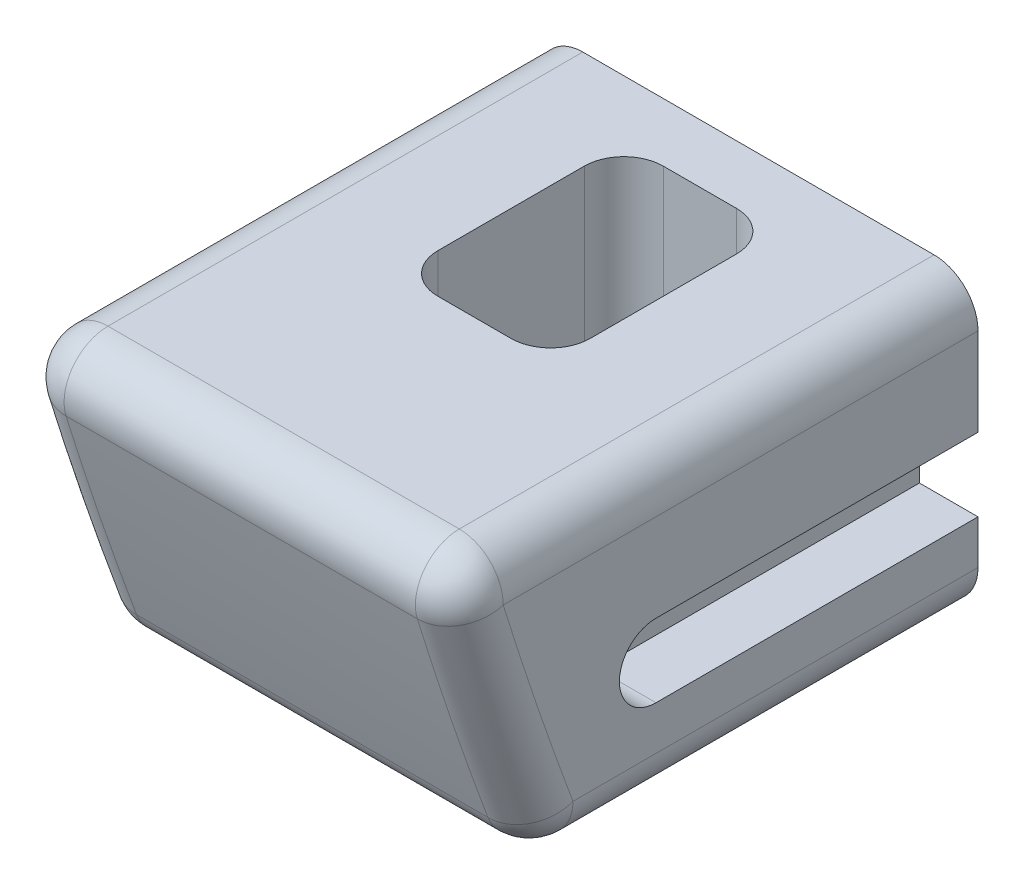
from build123d import *

# Parameters (mm, degrees)
SKETCH1_W               = 15
SKETCH1_H               = 8
BOSS_EXTRUDE1_DEPTH     = 10
CUT_EXTRUDE1_DEPTH      = 9
BOSS_EXTRUDE2_DEPTH     = 15
CUT_EXTRUDE2_DEPTH      = 2
SKETCH6_R               = 0.8
CUT_EXTRUDE3_DEPTH      = 9
CUT_EXTRUDE3_DEPTH_BACK = 3
FILLET1_R               = 1.5


with BuildPart() as part:
    # Sketch1 → Boss-Extrude1 (new body)
    with BuildSketch(Plane.XY):
        with Locations((0, 4)):
            Rectangle(SKETCH1_W, SKETCH1_H)
    extrude(amount=BOSS_EXTRUDE1_DEPTH)

    # Sketch2 → Cut-Extrude1 (cut, through all)
    with BuildSketch(Plane(origin=(0, 8, 0), x_dir=(1, 0, 0), z_dir=(0, 1, 0))):
        with BuildLine():
            Line((-1.25, -2), (1.25, -2))
            ThreePointArc((1.25, -2), (2.204594155, -2.395405845), (2.6, -3.35))
            Line((2.6, -3.35), (2.6, -8.35))
            ThreePointArc((2.6, -8.35), (2.204594155, -9.304594155), (1.25, -9.7))
            Line((1.25, -9.7), (-1.25, -9.7))
            ThreePointArc((-1.25, -9.7), (-2.204594155, -9.304594155), (-2.6, -8.35))
            Line((-2.6, -8.35), (-2.6, -3.35))
            ThreePointArc((-2.6, -3.35), (-2.204594155, -2.395405845), (-1.25, -2))
        make_face()
    extrude(amount=-CUT_EXTRUDE1_DEPTH, mode=Mode.SUBTRACT)

    # Sketch3 → Boss-Extrude2 (add)
    with BuildSketch(Plane(origin=(-7.5, 0, 0), x_dir=(0, 0, -1), z_dir=(1, 0, 0))):
        with BuildLine():
            ThreePointArc((-18.235493239, 8), (-16.655013859, 2.966168092), (-14.873286259, -2))
            Line((-14.873286259, -2), (0, -2))
            Line((0, -2), (0, 0))
            Line((0, 0), (-10, 0))
            Line((-10, 0), (-10, 8))
            Line((-10, 8), (-15.107085438, 8))
            Line((-15.107085438, 8), (-18.235493239, 8))
        make_face()
    extrude(amount=BOSS_EXTRUDE2_DEPTH)

    # Sketch5 → Cut-Extrude2 (cut)
    with BuildSketch(Plane(origin=(7.5, 0, 0), x_dir=(0, 0, -1), z_dir=(1, 0, 0))):
        with BuildLine():
            Line((0, 1), (-11, 1))
            ThreePointArc((-11, 1), (-12.25, 2.25), (-11, 3.5))
            Line((-11, 3.5), (0, 3.5))
            Line((0, 3.5), (0, 1))
        make_face()
    cut_extrude2 = extrude(amount=-CUT_EXTRUDE2_DEPTH, mode=Mode.SUBTRACT)

    # Mirror1: Cut-Extrude2 across plane
    add(cut_extrude2.mirror(Plane(origin=(0, 0, 0), x_dir=(0, 0, 1), z_dir=(1, 0, 0))), mode=Mode.SUBTRACT)

    # Sketch6 → Cut-Extrude3 (cut, two sides)
    with BuildSketch(Plane(origin=(0, 0, 0), x_dir=(1, 0, 0), z_dir=(0, 1, 0))) as cut_extrude3_sk:
        with Locations((-1.25, -3.35)):
            Circle(SKETCH6_R)
        with Locations((1.25, -3.35)):
            Circle(SKETCH6_R)
        with Locations((1.25, -5.85)):
            Circle(SKETCH6_R)
        with Locations((1.25, -8.35)):
            Circle(SKETCH6_R)
        with Locations((-1.25, -5.85)):
            Circle(SKETCH6_R)
        with Locations((-1.25, -8.35)):
            Circle(SKETCH6_R)
    extrude(amount=CUT_EXTRUDE3_DEPTH, mode=Mode.SUBTRACT)
    extrude(cut_extrude3_sk.sketch, amount=-CUT_EXTRUDE3_DEPTH_BACK, mode=Mode.SUBTRACT)

    # Fillet1
    fillet1_edges = [part.edges().sort_by_distance(p)[0] for p in [
        (-7.5, -2, 7.436643129),
        (0, -2, 14.873286259),
        (-7.5, 2.966168092, 16.655013859),
        (0, 8, 18.235493239),
        (7.5, 2.966168092, 16.655013859),
        (7.5, -2, 7.436643129),
        (-7.5, 8, 9.11774662),
        (7.5, 8, 9.11774662),
    ]]
    fillet(fillet1_edges, radius=FILLET1_R)


solid = part.part
